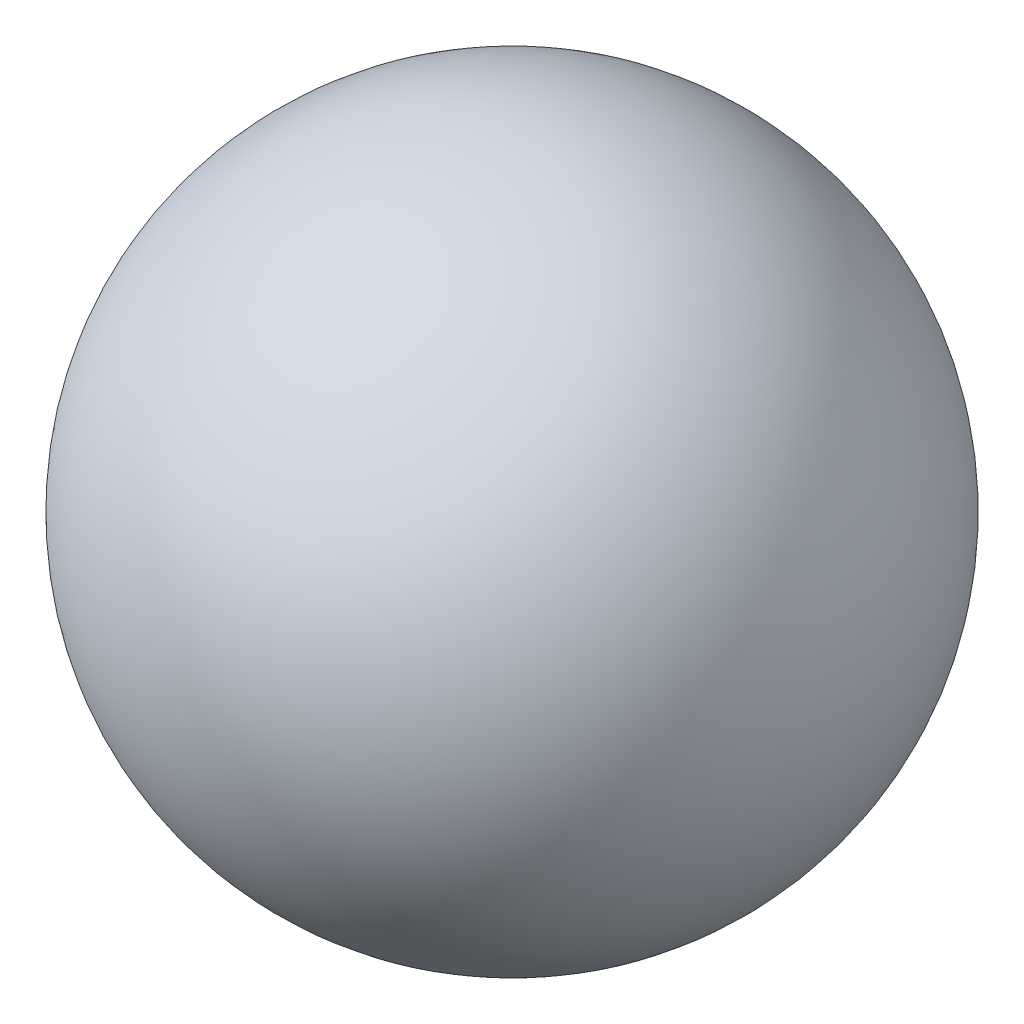
from build123d import *


with BuildPart() as part:
    # Sketch1 → Revolve1 (revolve)
    with BuildSketch(Plane.XY):
        with BuildLine():
            Line((0, 25.4), (0, -25.4))
            ThreePointArc((0, -25.4), (25.4, 0), (0, 25.4))
        make_face()
    revolve(axis=Axis((0, 25.4, 0), (0, -1, 0)))


solid = part.part
